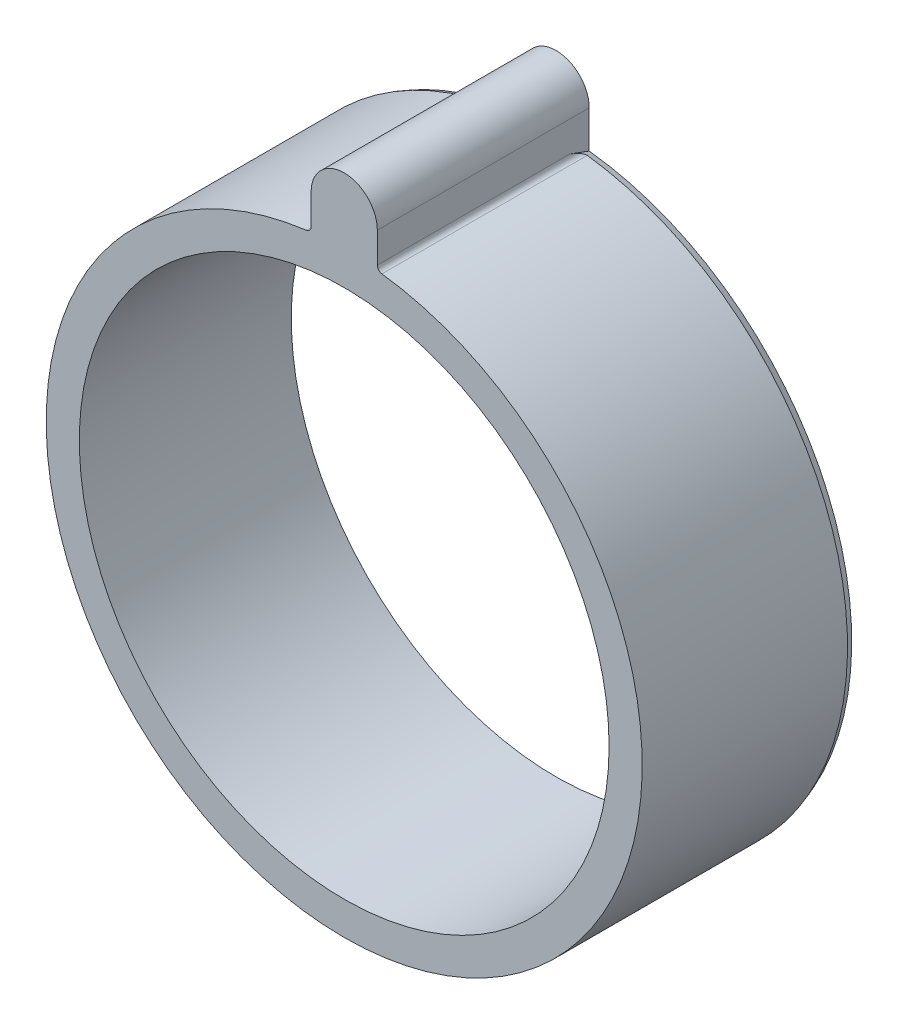
from build123d import *

# Parameters (mm, degrees)
SKETCH1_R      = 22.5
SKETCH1_R_2    = 20
EXTRUDE1_DEPTH = 16
EXTRUDE2_DEPTH = 16
CHAMFER1_SIZE  = 0.5
CHAMFER1_SIZE2 = 0.181985117
FILLET1_R      = 0.4


with BuildPart() as part:
    # Sketch1 → Extrude1 (new body)
    with BuildSketch(Plane.XY):
        Circle(SKETCH1_R)
        Circle(SKETCH1_R_2, mode=Mode.SUBTRACT)
    extrude(amount=EXTRUDE1_DEPTH)

    # Sketch3 → Extrude2 (add)
    with BuildSketch(Plane.XY.offset(16)):
        with BuildLine():
            Line((2.5, 25), (2.5, 22.360679775))
            ThreePointArc((2.5, 22.360679775), (0, 22.5), (-2.5, 22.360679775))
            Line((-2.5, 22.360679775), (-2.5, 25))
            ThreePointArc((-2.5, 25), (0, 27.5), (2.5, 25))
        make_face()
    extrude(amount=-EXTRUDE2_DEPTH)

    # Chamfer1
    chamfer1_edges = [part.edges().sort_by_distance(p)[0] for p in [
        (0, -22.5, 0),
    ]]
    chamfer1_side = [part.faces().sort_by_distance(p)[0] for p in [
        (0, -22.5, 8),
    ]]
    chamfer(chamfer1_edges, length=CHAMFER1_SIZE, length2=CHAMFER1_SIZE2, reference=chamfer1_side[0])

    # Fillet1
    fillet1_edges = [part.edges().sort_by_distance(p)[0] for p in [
        (2.5, 22.360679775, 8.25),
        (-2.5, 22.360679775, 8.25),
    ]]
    fillet(fillet1_edges, radius=FILLET1_R)


solid = part.part
